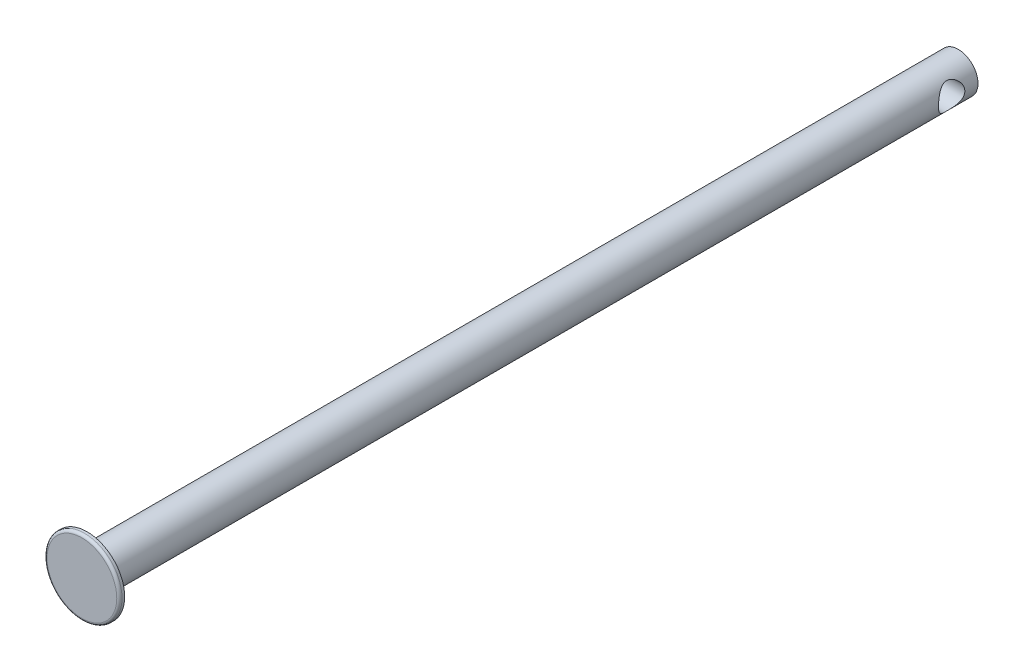
from build123d import *

# Parameters (mm, degrees)
IZIM1_R                     = 7.5
Y_KSEKLIK_EKSTR_ZYON1_DEPTH = 331
IZIM2_R                     = 14.25
Y_KSEKLIK_EKSTR_ZYON2_DEPTH = 2
RADYUS1_R                   = 1
IZIM6_R                     = 5
KES_EKSTR_ZYON1_DEPTH       = 22


with BuildPart() as part:
    # Çizim1 → Yükseklik-Ekstrüzyon1 (new body)
    with BuildSketch(Plane.XY):
        Circle(IZIM1_R)
    extrude(amount=Y_KSEKLIK_EKSTR_ZYON1_DEPTH)

    # Çizim2 → Yükseklik-Ekstrüzyon2 (add)
    with BuildSketch(Plane.XY.offset(331)):
        Circle(IZIM2_R)
    extrude(amount=Y_KSEKLIK_EKSTR_ZYON2_DEPTH)

    # Radyus1
    radyus1_edges = [part.edges().sort_by_distance(p)[0] for p in [
        (-14.25, 0, 333),
    ]]
    fillet(radyus1_edges, radius=RADYUS1_R)

    # Çizim6 → Kes-Ekstrüzyon1 (cut, symmetric)
    with BuildSketch(Plane(origin=(0, 0, 0), x_dir=(0, 0, -1), z_dir=(1, 0, 0))):
        with Locations((-10, 0)):
            Circle(IZIM6_R)
    extrude(amount=KES_EKSTR_ZYON1_DEPTH, both=True, mode=Mode.SUBTRACT)


solid = part.part
